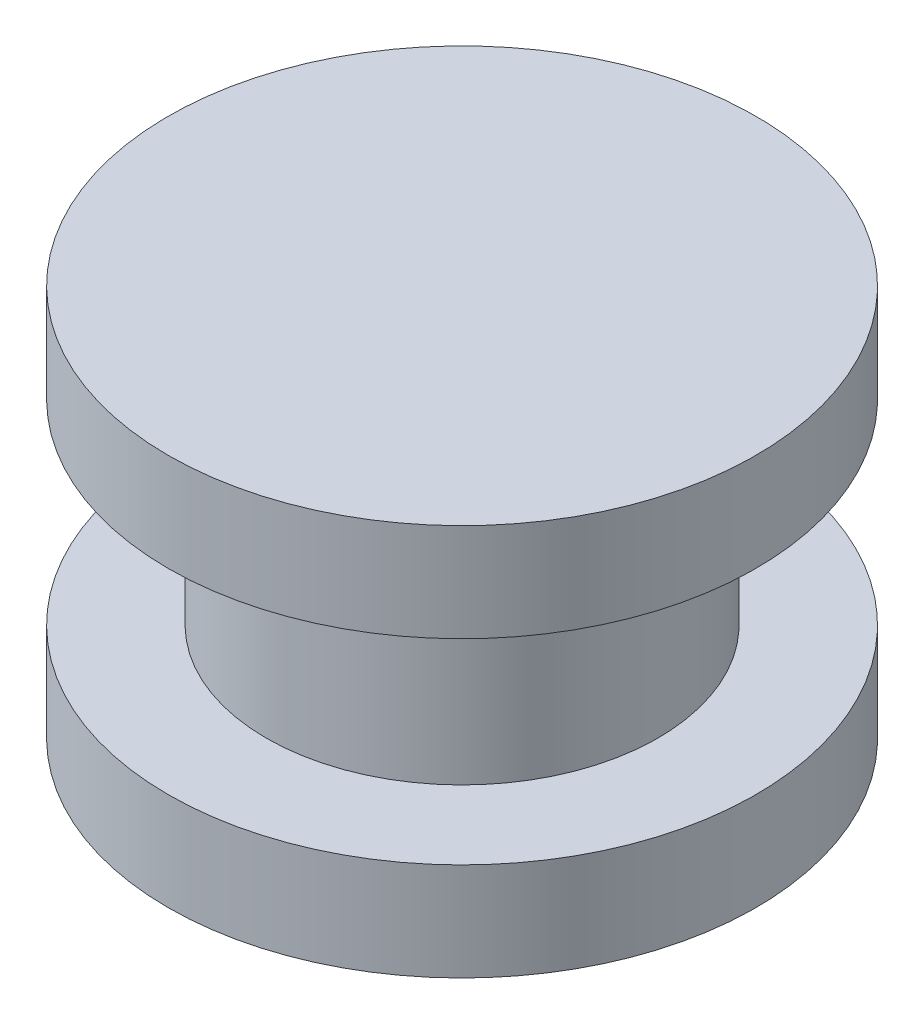
from build123d import *

# Parameters (mm, degrees)
SKETCH1_R           = 3
BOSS_EXTRUDE1_DEPTH = 1
SKETCH2_R           = 2
BOSS_EXTRUDE2_DEPTH = 2
SKETCH3_R           = 3
BOSS_EXTRUDE3_DEPTH = 1


with BuildPart() as part:
    # Sketch1 → Boss-Extrude1 (new body)
    with BuildSketch(Plane(origin=(0, 0, 0), x_dir=(1, 0, 0), z_dir=(0, 1, 0))):
        Circle(SKETCH1_R)
    extrude(amount=BOSS_EXTRUDE1_DEPTH)

    # Sketch2 → Boss-Extrude2 (add)
    with BuildSketch(Plane(origin=(0, 1, 0), x_dir=(1, 0, 0), z_dir=(0, 1, 0))):
        Circle(SKETCH2_R)
    extrude(amount=BOSS_EXTRUDE2_DEPTH)

    # Sketch3 → Boss-Extrude3 (add)
    with BuildSketch(Plane(origin=(0, 3, 0), x_dir=(1, 0, 0), z_dir=(0, 1, 0))):
        Circle(SKETCH3_R)
    extrude(amount=BOSS_EXTRUDE3_DEPTH)


solid = part.part
